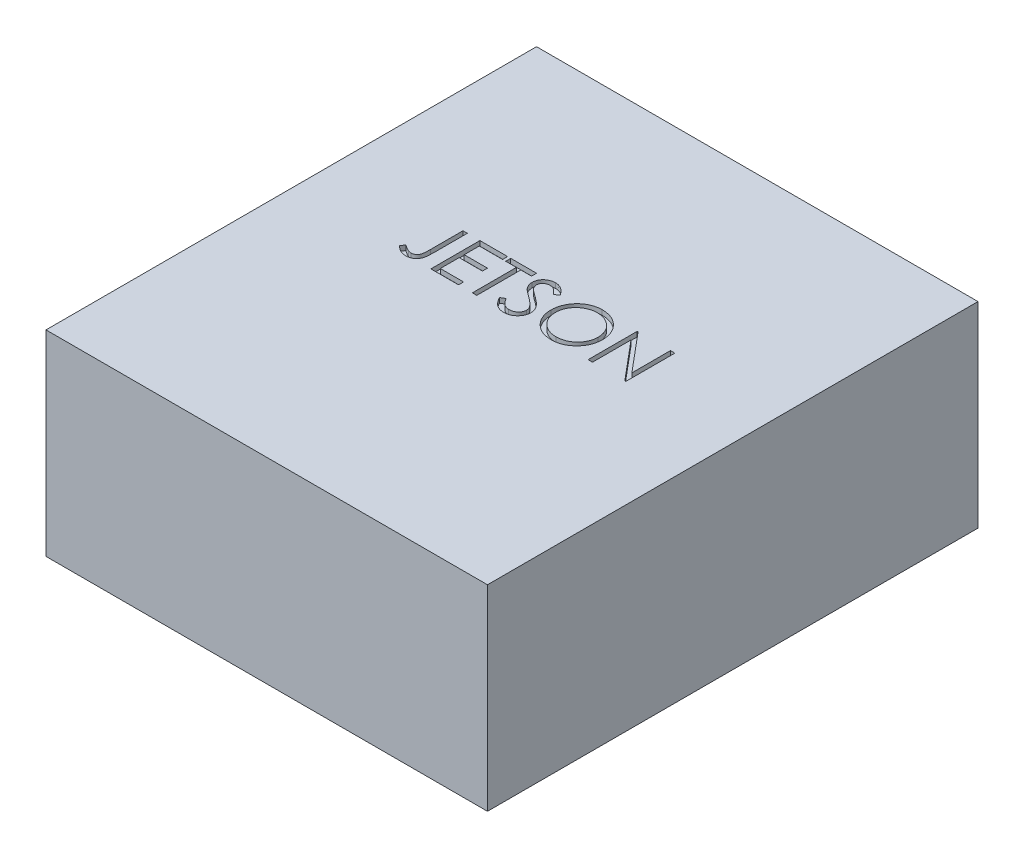
from build123d import *

# Parameters (mm, degrees)
SKETCH1_W           = 90
SKETCH1_H           = 100
BOSS_EXTRUDE1_DEPTH = 40
CUT_EXTRUDE1_DEPTH  = 1


with BuildPart() as part:
    # Sketch1 → Boss-Extrude1 (new body)
    with BuildSketch(Plane(origin=(0, 0, 0), x_dir=(1, 0, 0), z_dir=(0, 1, 0))):
        with Locations((45, 50)):
            Rectangle(SKETCH1_W, SKETCH1_H)
    extrude(amount=BOSS_EXTRUDE1_DEPTH)

    # Sketch2 → Cut-Extrude1 (cut)
    with BuildSketch(Plane(origin=(0, 40, 0), x_dir=(1, 0, 0), z_dir=(0, 1, 0))):
        with BuildLine():
            Line((25, 60), (25.897435897, 60))
            Line((25.897435897, 60), (25.897435897, 53.247195513))
            add(Edge.make_bspline(
                [(25.897435897, 53.247195513), (25.896538987, 53.122323596), (25.89481681, 52.882554278), (25.885347065, 52.53720029), (25.867822843, 52.221855472), (25.842294236, 51.935802767), (25.808236428, 51.679938323), (25.769262061, 51.452285129), (25.722082636, 51.25474318), (25.65103559, 51.032927878), (25.534538594, 50.789659864), (25.359204199, 50.526930862), (25.141396209, 50.297121118), (24.889107543, 50.097541904), (24.600133189, 49.938521243), (24.280423991, 49.82436359), (23.931948027, 49.754732571), (23.690235992, 49.747378557), (23.565705128, 49.743589744)],
                knots=[0, 0, 0, 0, 1.237770943, 2.376671248, 3.424123796, 4.367912054, 5.222547132, 5.982086412, 6.656319012, 7.234008312, 8.288027371, 9.317870876, 10.352700517, 11.413286737, 12.494591526, 13.606319346, 14.766767577, 16, 16, 16, 16], degree=3))
            add(Edge.make_bspline(
                [(23.565705128, 49.743589744), (23.468681247, 49.746677198), (23.273462773, 49.752889362), (22.982917891, 49.803522827), (22.69319796, 49.881568665), (22.402765249, 49.995861795), (22.105881702, 50.151306362), (21.798526426, 50.354691553), (21.47674588, 50.605638771), (21.264793634, 50.797175187), (21.153846154, 50.897435897)],
                knots=[0, 0, 0, 0, 0.848567217, 1.707373443, 2.573483905, 3.470863513, 4.432650262, 5.500696352, 6.691726801, 8, 8, 8, 8], degree=3))
            Line((21.153846154, 50.897435897), (21.682692308, 51.666666667))
            add(Edge.make_bspline(
                [(21.682692308, 51.666666667), (21.804699962, 51.582531249), (22.035066322, 51.42367261), (22.373650439, 51.219310894), (22.673642305, 51.044096136), (22.869879297, 50.95480391), (22.960737179, 50.913461538)],
                knots=[0, 0, 0, 0, 1.196737151, 2.259595785, 3.194191475, 4, 4, 4, 4], degree=3))
            add(Edge.make_bspline(
                [(22.960737179, 50.913461538), (23.015835213, 50.891863089), (23.123894725, 50.84950372), (23.289109238, 50.802229725), (23.453380772, 50.776394268), (23.562288469, 50.771590459), (23.615785256, 50.769230769)],
                knots=[0, 0, 0, 0, 1.051806502, 2.062826769, 3.048436908, 4, 4, 4, 4], degree=3))
            add(Edge.make_bspline(
                [(23.615785256, 50.769230769), (23.684878938, 50.772152869), (23.82145167, 50.777928783), (24.019920224, 50.828926712), (24.209800313, 50.906767864), (24.38428505, 51.020742989), (24.545100441, 51.156261334), (24.677794229, 51.320135644), (24.788414927, 51.501752741), (24.85498548, 51.673671181), (24.897399114, 51.830461553), (24.924318048, 51.974556227), (24.947857077, 52.143017594), (24.968375797, 52.336046738), (24.98038857, 52.554030115), (24.993866493, 52.796327667), (24.998738667, 53.063550273), (24.999566726, 53.249867278), (25, 53.347355769)],
                knots=[0, 0, 0, 0, 0.997221856, 1.971139923, 2.944579524, 3.951425367, 4.971190333, 5.972282193, 6.985401279, 8.033996657, 8.624075553, 9.332086008, 10.151144245, 11.082816738, 12.137127781, 13.306538797, 14.590673636, 16, 16, 16, 16], degree=3))
            Line((25, 53.347355769), (25, 60))
        make_face()
        Polygon((28.461538462, 60), (34.102564103, 60), (34.102564103, 58.974358974), (29.358974359, 58.974358974), (29.358974359, 55.897435897), (34.102564103, 55.897435897), (34.102564103, 54.871794872), (29.358974359, 54.871794872), (29.358974359, 51.025641026), (34.102564103, 51.025641026), (34.102564103, 50), (28.461538462, 50), align=None)
        Polygon((34.743589744, 58.974358974), (34.743589744, 60), (40, 60), (40, 58.974358974), (37.820512821, 58.974358974), (37.820512821, 50), (36.923076923, 50), (36.923076923, 58.974358974), align=None)
        with BuildLine():
            Line((40.512820513, 51.929086538), (41.358173077, 52.435897436))
            add(Edge.make_bspline(
                [(41.358173077, 52.435897436), (41.436796612, 52.304284907), (41.587436271, 52.052120382), (41.838725868, 51.711383124), (42.099105615, 51.421776961), (42.37050371, 51.184986654), (42.651263562, 50.998561264), (42.943218002, 50.866554887), (43.245383175, 50.784223529), (43.451022665, 50.774223282), (43.553685897, 50.769230769)],
                knots=[0, 0, 0, 0, 1.272034388, 2.437168799, 3.508375237, 4.49857839, 5.41946034, 6.295179144, 7.148887113, 8, 8, 8, 8], degree=3))
            add(Edge.make_bspline(
                [(43.553685897, 50.769230769), (43.641362642, 50.771672691), (43.815181993, 50.776513806), (44.071074116, 50.823030383), (44.319593551, 50.894493608), (44.55561823, 50.996839127), (44.775891415, 51.120663372), (44.969053401, 51.270223879), (45.136042296, 51.437670181), (45.272639766, 51.624477766), (45.377439867, 51.825383905), (45.457988634, 52.031600909), (45.502688845, 52.246368247), (45.509422426, 52.390969569), (45.512820513, 52.463942308)],
                knots=[0, 0, 0, 0, 1.095163259, 2.171163733, 3.241058638, 4.321873601, 5.38011039, 6.391990106, 7.366004449, 8.327778327, 9.272591725, 10.192022065, 11.087607919, 12, 12, 12, 12], degree=3))
            add(Edge.make_bspline(
                [(45.512820513, 52.463942308), (45.508608197, 52.547201878), (45.500045173, 52.716456419), (45.427669516, 52.966169713), (45.313814525, 53.213291342), (45.2087784, 53.3661521), (45.154246795, 53.445512821)],
                knots=[0, 0, 0, 0, 0.938893495, 1.908633276, 2.914225137, 4, 4, 4, 4], degree=3))
            add(Edge.make_bspline(
                [(45.154246795, 53.445512821), (45.109473611, 53.502789459), (45.015477914, 53.623034598), (44.85388502, 53.802020985), (44.664267551, 53.986645039), (44.453114537, 54.183956631), (44.212734283, 54.384778907), (43.950655671, 54.598688272), (43.660187502, 54.817549921), (43.456474655, 54.96432868), (43.351362179, 55.040064103)],
                knots=[0, 0, 0, 0, 0.722233717, 1.516239348, 2.393582979, 3.351407094, 4.387010283, 5.505090956, 6.712668013, 8, 8, 8, 8], degree=3))
            add(Edge.make_bspline(
                [(43.351362179, 55.040064103), (43.246150762, 55.115002924), (43.044994543, 55.258280245), (42.763684308, 55.470921057), (42.512128699, 55.665332112), (42.291445795, 55.843343575), (42.101732661, 56.004979589), (41.941494344, 56.148687987), (41.814812752, 56.278355303), (41.744368236, 56.362473423), (41.712740385, 56.400240385)],
                knots=[0, 0, 0, 0, 1.452282411, 2.77665338, 3.964542531, 5.026858415, 5.96415736, 6.766646006, 7.446254459, 8, 8, 8, 8], degree=3))
            add(Edge.make_bspline(
                [(41.712740385, 56.400240385), (41.668533113, 56.45910049), (41.581593579, 56.574856786), (41.466833563, 56.755784951), (41.369293098, 56.940994281), (41.292829292, 57.130982466), (41.228440096, 57.323082262), (41.185131722, 57.519800107), (41.158013445, 57.720253303), (41.155236341, 57.855149019), (41.153846154, 57.922676282)],
                knots=[0, 0, 0, 0, 1.068054152, 2.10047183, 3.106115577, 4.101338837, 5.06977816, 6.043150881, 7.020423561, 8, 8, 8, 8], degree=3))
            add(Edge.make_bspline(
                [(41.153846154, 57.922676282), (41.157575322, 58.028475638), (41.164953951, 58.237812963), (41.227355429, 58.543615336), (41.325849411, 58.835576528), (41.463834805, 59.110806053), (41.641712956, 59.362137427), (41.847558597, 59.592461675), (42.092734272, 59.786086196), (42.361741767, 59.955263505), (42.656188544, 60.087680435), (42.964733983, 60.187568949), (43.287868474, 60.244166828), (43.506734573, 60.252289014), (43.617788462, 60.256410256)],
                knots=[0, 0, 0, 0, 1.005424448, 1.989358655, 2.955360095, 3.929531133, 4.905563448, 5.876582895, 6.856512386, 7.866279853, 8.892233794, 9.918561126, 10.94386622, 12, 12, 12, 12], degree=3))
            add(Edge.make_bspline(
                [(43.617788462, 60.256410256), (43.735628748, 60.252345823), (43.969975467, 60.244262963), (44.314687512, 60.173984302), (44.646575273, 60.057696668), (44.91355603, 59.925729074), (45.122506777, 59.793925029), (45.281857441, 59.673868388), (45.443335872, 59.535653792), (45.6082446, 59.378913089), (45.773789342, 59.202208086), (45.942427777, 59.006748975), (46.114554259, 58.793730244), (46.225285288, 58.641660242), (46.282051282, 58.563701923)],
                knots=[0, 0, 0, 0, 1.286793592, 2.559021753, 3.825965368, 5.121522368, 5.803751409, 6.523245864, 7.299691795, 8.125521123, 9.008227632, 9.944561021, 10.946284179, 12, 12, 12, 12], degree=3))
            Line((46.282051282, 58.563701923), (45.470753205, 57.948717949))
            add(Edge.make_bspline(
                [(45.470753205, 57.948717949), (45.421764827, 58.011828493), (45.327424664, 58.133364645), (45.184197558, 58.303568404), (45.049201421, 58.45904406), (44.916200279, 58.594087282), (44.792218475, 58.716093378), (44.671884068, 58.820549826), (44.556928779, 58.908480098), (44.41202332, 59.002318841), (44.229972696, 59.095337423), (44.00144545, 59.174049074), (43.762627521, 59.221349251), (43.599971431, 59.227603216), (43.517628205, 59.230769231)],
                knots=[0, 0, 0, 0, 1.181633172, 2.275549214, 3.290209073, 4.226197932, 5.078386478, 5.862611352, 6.581680152, 7.217281963, 8.414376989, 9.595101626, 10.782541182, 12, 12, 12, 12], degree=3))
            add(Edge.make_bspline(
                [(43.517628205, 59.230769231), (43.414323855, 59.227307231), (43.215111149, 59.22063109), (42.932281902, 59.147716847), (42.677727831, 59.032911531), (42.459006216, 58.872011594), (42.276900568, 58.681380186), (42.145170686, 58.462012029), (42.065884501, 58.219776593), (42.056209416, 58.050800432), (42.051282051, 57.96474359)],
                knots=[0, 0, 0, 0, 1.14458467, 2.207223713, 3.21896685, 4.227309161, 5.202851033, 6.127160689, 7.046193047, 8, 8, 8, 8], degree=3))
            add(Edge.make_bspline(
                [(42.051282051, 57.96474359), (42.05240527, 57.911167937), (42.054653545, 57.803929024), (42.08601011, 57.64549639), (42.126293907, 57.487463992), (42.190129997, 57.330542326), (42.278259436, 57.171987015), (42.39398851, 57.009067765), (42.53974083, 56.840348597), (42.651389437, 56.730613243), (42.710336538, 56.672676282)],
                knots=[0, 0, 0, 0, 0.858281714, 1.717966888, 2.583508476, 3.4729293, 4.427298488, 5.488583878, 6.674047936, 8, 8, 8, 8], degree=3))
            add(Edge.make_bspline(
                [(42.710336538, 56.672676282), (42.732226174, 56.653141923), (42.784230937, 56.606732756), (42.879305011, 56.530754811), (43.004855863, 56.437032605), (43.157605009, 56.321068843), (43.3403689, 56.18655038), (43.553167631, 56.035197203), (43.793629154, 55.862095891), (43.964263199, 55.741074346), (44.054487179, 55.677083333)],
                knots=[0, 0, 0, 0, 0.420754252, 0.999615792, 1.744751191, 2.668019286, 3.750313428, 4.999500688, 6.413464383, 8, 8, 8, 8], degree=3))
            add(Edge.make_bspline(
                [(44.054487179, 55.677083333), (44.16301836, 55.59810802), (44.37317395, 55.445183272), (44.672195607, 55.215424187), (44.943320773, 54.990716276), (45.187501355, 54.772494542), (45.407149664, 54.562414276), (45.599828866, 54.357948047), (45.767502239, 54.160560696), (45.948014291, 53.907496194), (46.132465204, 53.596693096), (46.290869511, 53.215898129), (46.390750504, 52.833622928), (46.403811977, 52.576689109), (46.41025641, 52.449919872)],
                knots=[0, 0, 0, 0, 1.163667725, 2.253281268, 3.268753668, 4.215851969, 5.092017293, 5.902905408, 6.650798638, 7.335211899, 8.59617414, 9.77448103, 10.901945474, 12, 12, 12, 12], degree=3))
            add(Edge.make_bspline(
                [(46.41025641, 52.449919872), (46.408378873, 52.3602674), (46.404660258, 52.182703447), (46.36191479, 51.921974656), (46.299287176, 51.6687436), (46.204895079, 51.426140421), (46.089686055, 51.189726814), (45.943496775, 50.965704241), (45.774046248, 50.749114531), (45.579664062, 50.545733127), (45.366961484, 50.35902971), (45.142150928, 50.192946677), (44.904864434, 50.054465753), (44.656389243, 49.941463347), (44.396668281, 49.853081869), (44.125788899, 49.7890451), (43.843304581, 49.749743068), (43.651303205, 49.74566375), (43.553685897, 49.743589744)],
                knots=[0, 0, 0, 0, 0.983748083, 1.948392443, 2.894712957, 3.844097841, 4.80183111, 5.778335162, 6.776009319, 7.81870978, 8.863265674, 9.881300176, 10.883814829, 11.87499822, 12.874611388, 13.892143829, 14.928324115, 16, 16, 16, 16], degree=3))
            add(Edge.make_bspline(
                [(43.553685897, 49.743589744), (43.478156346, 49.745050262), (43.32804846, 49.747952906), (43.106021369, 49.773613708), (42.888479686, 49.809919718), (42.678153166, 49.867559918), (42.472331989, 49.937494138), (42.271911319, 50.02360366), (42.076794023, 50.126795664), (41.885886643, 50.244781448), (41.699674716, 50.38208929), (41.519904807, 50.542013566), (41.340678563, 50.72014358), (41.167286002, 50.921316618), (40.996219875, 51.142282569), (40.830852991, 51.385108807), (40.667762369, 51.648472675), (40.565432461, 51.833801492), (40.512820513, 51.929086538)],
                knots=[0, 0, 0, 0, 0.915332311, 1.819136955, 2.706846663, 3.586547465, 4.459518054, 5.340707479, 6.227863349, 7.133153174, 8.059268498, 9.028702269, 10.047606654, 11.120612155, 12.245963614, 13.433783089, 14.680604001, 16, 16, 16, 16], degree=3))
        make_face()
        with BuildLine():
            add(Edge.make_bspline(
                [(53.141025641, 60.256410256), (53.326191658, 60.251720315), (53.689872992, 60.242508884), (54.2243727, 60.17199716), (54.734644401, 60.050010331), (55.224844797, 59.887544667), (55.689110445, 59.670817852), (56.130935852, 59.408860285), (56.549269777, 59.098927546), (56.938473724, 58.743415469), (57.294636439, 58.356605601), (57.608424686, 57.943811572), (57.871402668, 57.50752928), (58.08736206, 57.049069763), (58.256786659, 56.569469855), (58.373698212, 56.066172704), (58.448378641, 55.542439304), (58.457109434, 55.185219691), (58.461538462, 55.00400641)],
                knots=[0, 0, 0, 0, 1.065120563, 2.091984664, 3.0946048, 4.079830382, 5.057816894, 6.036188127, 7.030412546, 8.04752943, 9.064399622, 10.05169764, 11.02544977, 11.989514704, 12.962713494, 13.945757189, 14.957906945, 16, 16, 16, 16], degree=3))
            add(Edge.make_bspline(
                [(58.461538462, 55.00400641), (58.457110083, 54.824127992), (58.448381236, 54.469566791), (58.3736133, 53.94915695), (58.2563533, 53.448897818), (58.088935396, 52.969624524), (57.874005458, 52.510831485), (57.609276398, 52.073725902), (57.297444367, 51.658164478), (56.94256765, 51.26869972), (56.55570753, 50.91156409), (56.14076391, 50.600367302), (55.70706871, 50.332584089), (55.249040973, 50.118916449), (54.772755153, 49.948139534), (54.273948516, 49.831703448), (53.754958362, 49.75659761), (53.401041208, 49.747973279), (53.221153846, 49.743589744)],
                knots=[0, 0, 0, 0, 1.043624062, 2.057103931, 3.04512605, 4.022047818, 4.998200453, 5.980619268, 6.982898556, 8.009068085, 9.034988726, 10.034168286, 11.015286542, 11.987931943, 12.962482838, 13.94673481, 14.956375938, 16, 16, 16, 16], degree=3))
            add(Edge.make_bspline(
                [(53.221153846, 49.743589744), (53.039941506, 49.748016563), (52.682723746, 49.756743003), (52.158332217, 49.831547017), (51.65468152, 49.94852217), (51.173211945, 50.115691988), (50.713655003, 50.331741219), (50.27511191, 50.595182302), (49.859342918, 50.907774134), (49.469795071, 51.262535775), (49.11336879, 51.64874021), (48.802627717, 52.062552367), (48.539127393, 52.495853672), (48.323803586, 52.949846598), (48.153333702, 53.422336434), (48.037034222, 53.916474941), (47.961788644, 54.429444958), (47.953117654, 54.778710382), (47.948717949, 54.955929487)],
                knots=[0, 0, 0, 0, 1.053102029, 2.075944431, 3.073151272, 4.055350789, 5.033113405, 6.020478099, 7.024410459, 8.052272461, 9.079885166, 10.07527673, 11.055994387, 12.023226415, 12.992069828, 13.970394897, 14.97016774, 16, 16, 16, 16], degree=3))
            add(Edge.make_bspline(
                [(47.948717949, 54.955929487), (47.950245479, 55.07487997), (47.953281268, 55.311280323), (47.989828961, 55.662327752), (48.042862393, 56.007729632), (48.118867858, 56.346503769), (48.21827262, 56.677820868), (48.335564127, 57.003965905), (48.478820828, 57.321633687), (48.640765537, 57.632329092), (48.82151356, 57.931208822), (49.021158558, 58.213721917), (49.232688182, 58.482239051), (49.464583593, 58.729801919), (49.709202008, 58.963612366), (49.970511659, 59.180077272), (50.246918072, 59.38114856), (50.539610586, 59.562349535), (50.841377085, 59.726232776), (51.152453593, 59.866866636), (51.468615226, 59.987569669), (51.791342791, 60.085400598), (52.119779283, 60.162634987), (52.454641525, 60.215227426), (52.795662743, 60.251868334), (53.025409368, 60.254889768), (53.141025641, 60.256410256)],
                knots=[0, 0, 0, 0, 1.037015668, 2.060948919, 3.074880161, 4.083647147, 5.086022904, 6.090072063, 7.104153813, 8.122640571, 9.144368836, 10.147691507, 11.138137339, 12.123020368, 13.103399296, 14.087645067, 15.080126199, 16.082011238, 17.087798457, 18.072939717, 19.057185487, 20.037253025, 21.01195951, 21.997135196, 22.992090687, 24, 24, 24, 24], degree=3))
        make_face()
        with BuildLine():
            add(Edge.make_bspline(
                [(53.185096154, 59.230769231), (53.090197201, 59.229612401), (52.901306535, 59.227309802), (52.620493575, 59.196979186), (52.343373764, 59.153750932), (52.069889872, 59.092089444), (51.801186188, 59.008077865), (51.53475807, 58.911389556), (51.273035059, 58.793615011), (51.01688118, 58.660550142), (50.768552393, 58.513267511), (50.534230389, 58.350491033), (50.313308549, 58.176038021), (50.106327787, 57.989501343), (49.913895867, 57.789931052), (49.732225291, 57.580352663), (49.568597915, 57.354775832), (49.418639124, 57.119317526), (49.284445295, 56.874284437), (49.16511571, 56.622256259), (49.067504256, 56.361177154), (48.987897467, 56.093879561), (48.921898007, 55.820786819), (48.880086796, 55.539827251), (48.849422912, 55.252412645), (48.847251925, 55.058178777), (48.846153846, 54.959935897)],
                knots=[0, 0, 0, 0, 1.008559885, 2.007477868, 2.99961109, 3.989939068, 4.984837346, 5.991145699, 7.001802488, 8.033829008, 9.059044045, 10.069351652, 11.065060232, 12.050310815, 13.029377138, 14.011219647, 14.996725999, 15.989392538, 16.977580475, 17.965360261, 18.951710183, 19.937753436, 20.929683414, 21.935841486, 22.955955122, 24, 24, 24, 24], degree=3))
            add(Edge.make_bspline(
                [(48.846153846, 54.959935897), (48.849796309, 54.815472409), (48.85696216, 54.531268037), (48.919698075, 54.114787626), (49.016332287, 53.714535379), (49.158781906, 53.332701353), (49.336926519, 52.966003402), (49.557003348, 52.617694531), (49.817743593, 52.287680605), (50.113925097, 51.97826555), (50.437704259, 51.695848967), (50.781512059, 51.447953514), (51.141665223, 51.238209943), (51.519102945, 51.067338307), (51.9118102, 50.931939056), (52.322317488, 50.839142968), (52.74789023, 50.778070238), (53.037977816, 50.772205221), (53.185096154, 50.769230769)],
                knots=[0, 0, 0, 0, 1.032063989, 2.030389145, 3.003944642, 3.970395727, 4.937377036, 5.913328081, 6.909231446, 7.93887556, 8.970685674, 9.976071282, 10.964166581, 11.944589148, 12.933237628, 13.927779006, 14.949070134, 16, 16, 16, 16], degree=3))
            add(Edge.make_bspline(
                [(53.185096154, 50.769230769), (53.283980444, 50.770589353), (53.480097691, 50.773283833), (53.771799183, 50.80042291), (54.058245503, 50.843942537), (54.339034874, 50.906601553), (54.613848621, 50.985022142), (54.883833772, 51.078187079), (55.146114602, 51.19441909), (55.403999853, 51.322841809), (55.650846257, 51.469242259), (55.886490635, 51.626494115), (56.104993435, 51.800690174), (56.311819353, 51.984455353), (56.505041322, 52.181494918), (56.683352705, 52.391552695), (56.846153083, 52.615954573), (56.99605493, 52.851055732), (57.129778538, 53.096759311), (57.24629025, 53.349701248), (57.345136295, 53.609258703), (57.424932023, 53.875806051), (57.487461914, 54.148837047), (57.530547399, 54.42871727), (57.560685795, 54.71488682), (57.562957444, 54.908440694), (57.564102564, 55.006009615)],
                knots=[0, 0, 0, 0, 1.047197238, 2.076906641, 3.100256066, 4.114471768, 5.12198147, 6.126382909, 7.136867548, 8.15857795, 9.17633901, 10.174870724, 11.156907918, 12.133735059, 13.104061851, 14.077631395, 15.04955518, 16.038496417, 17.029181396, 18.010275684, 18.986308667, 19.968651475, 20.955262928, 21.950658345, 22.966943676, 24, 24, 24, 24], degree=3))
            add(Edge.make_bspline(
                [(57.564102564, 55.006009615), (57.562956527, 55.102911056), (57.560683151, 55.295132914), (57.530561795, 55.579306681), (57.487416394, 55.857172999), (57.425237228, 56.127641008), (57.345093932, 56.390779651), (57.246272988, 56.646341787), (57.129743561, 56.895279487), (56.996005777, 57.136977479), (56.845674853, 57.368905301), (56.681405586, 57.59062648), (56.500361734, 57.79797717), (56.307715949, 57.996076295), (56.098656277, 58.180698837), (55.874129722, 58.351906039), (55.636862071, 58.51382968), (55.385641399, 58.659902714), (55.12637296, 58.794800521), (54.86033308, 58.910374816), (54.590535652, 59.008580871), (54.31766676, 59.092343629), (54.039429679, 59.153509429), (53.757704453, 59.197018143), (53.472880858, 59.227299246), (53.281328801, 59.229608899), (53.185096154, 59.230769231)],
                knots=[0, 0, 0, 0, 1.02996197, 2.043119294, 3.035359645, 4.018872909, 4.991431989, 5.957985074, 6.929999688, 7.912076566, 8.892894881, 9.867085534, 10.843653904, 11.817741046, 12.803660682, 13.806313499, 14.818574707, 15.856120519, 16.894564902, 17.924820532, 18.937903209, 19.946497019, 20.957711757, 21.963978472, 22.977135795, 24, 24, 24, 24], degree=3))
        make_face(mode=Mode.SUBTRACT)
        Polygon((60.512820513, 50), (60.512820513, 60), (60.701121795, 60), (67.307692308, 52.129407051), (67.307692308, 60), (68.205128205, 60), (68.205128205, 50), (68.000801282, 50), (61.41025641, 57.852564103), (61.41025641, 50), align=None)
    extrude(amount=-CUT_EXTRUDE1_DEPTH, mode=Mode.SUBTRACT)


solid = part.part
